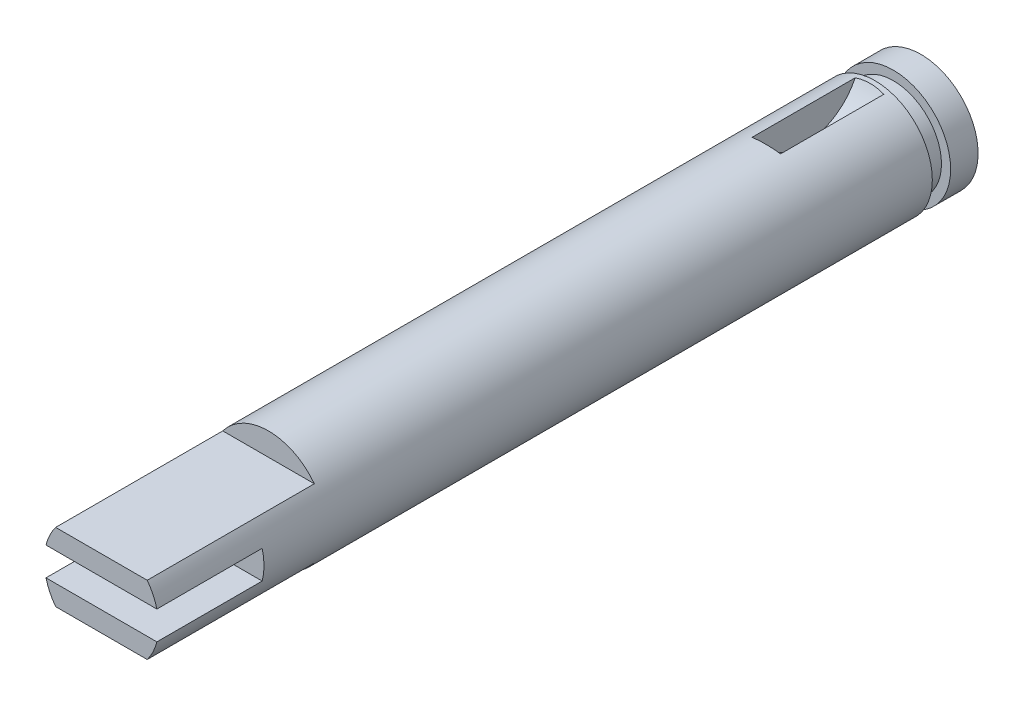
from build123d import *

# Parameters (mm, degrees)
SKETCH1_R           = 3.175
EXTRUDE1_DEPTH      = 42.926
SKETCH4_R           = 3.175
EXTRUDE2_DEPTH      = 0.79375
EXTRUDE2_DEPTH_BACK = 0.79375
SKETCH5_R           = 3.175
EXTRUDE3_DEPTH      = 2.54
SKETCH6_OUTSIDE_W   = 17.618
SKETCH6_OUTSIDE_H   = 17.618
SKETCH6_OUTSIDE_R   = 2.667
EXTRUDE4_DEPTH      = 1.016
EXTRUDE5_DEPTH      = 4.1750001
EXTRUDE5_DEPTH_BACK = 4.1750001
EXTRUDE6_DEPTH      = 4.1750001


with BuildPart() as part:
    # Sketch1 → Extrude1 (new body)
    with BuildSketch(Plane.XY):
        Circle(SKETCH1_R)
    extrude(amount=EXTRUDE1_DEPTH)

    # Sketch4 → Extrude2 (cut, two sides)
    with BuildSketch(Plane(origin=(0, 0, 0), x_dir=(0, 0, -1), z_dir=(1, 0, 0))) as extrude2_sk:
        with Locations((-3.175, 4.445)):
            Circle(SKETCH4_R)
    extrude(amount=EXTRUDE2_DEPTH, mode=Mode.SUBTRACT)
    extrude(extrude2_sk.sketch, amount=-EXTRUDE2_DEPTH_BACK, mode=Mode.SUBTRACT)

    # Sketch5 → Extrude3 (add)
    with BuildSketch(Plane(origin=(0, 0, 0), x_dir=(-1, 0, 0), z_dir=(0, 0, -1))):
        Circle(SKETCH5_R)
    extrude(amount=EXTRUDE3_DEPTH)

    # Sketch6 outside → Extrude4 (cut)
    with BuildSketch(Plane.XY):
        Rectangle(SKETCH6_OUTSIDE_W, SKETCH6_OUTSIDE_H)
        Circle(SKETCH6_OUTSIDE_R, mode=Mode.SUBTRACT)
    extrude(amount=-EXTRUDE4_DEPTH, mode=Mode.SUBTRACT)

    # Sketch7 → Extrude5 (cut, two sides)
    with BuildSketch(Plane(origin=(0, 0, 0), x_dir=(0, 0, -1), z_dir=(1, 0, 0))) as extrude5_sk:
        Polygon((-42.926, 0), (-42.926, 0.7874), (-37.084, 0.7874), (-37.084, 0), (-37.084, -0.7874), (-42.926, -0.7874), align=None)
    extrude(amount=EXTRUDE5_DEPTH, mode=Mode.SUBTRACT)
    extrude(extrude5_sk.sketch, amount=-EXTRUDE5_DEPTH_BACK, mode=Mode.SUBTRACT)

    # Sketch8 → Extrude6 (cut, symmetric)
    with BuildSketch(Plane(origin=(0, 0, 0), x_dir=(0, 0, -1), z_dir=(1, 0, 0))):
        Polygon((-42.926, 1.905), (-40.005, 1.905), (-33.655, 1.905), (-33.655, 3.175), (-42.926, 3.175), align=None)
    extrude6 = extrude(amount=EXTRUDE6_DEPTH, both=True, mode=Mode.SUBTRACT)

    # Mirror1: Extrude6 across plane
    add(extrude6.mirror(Plane.ZX), mode=Mode.SUBTRACT)


solid = part.part
